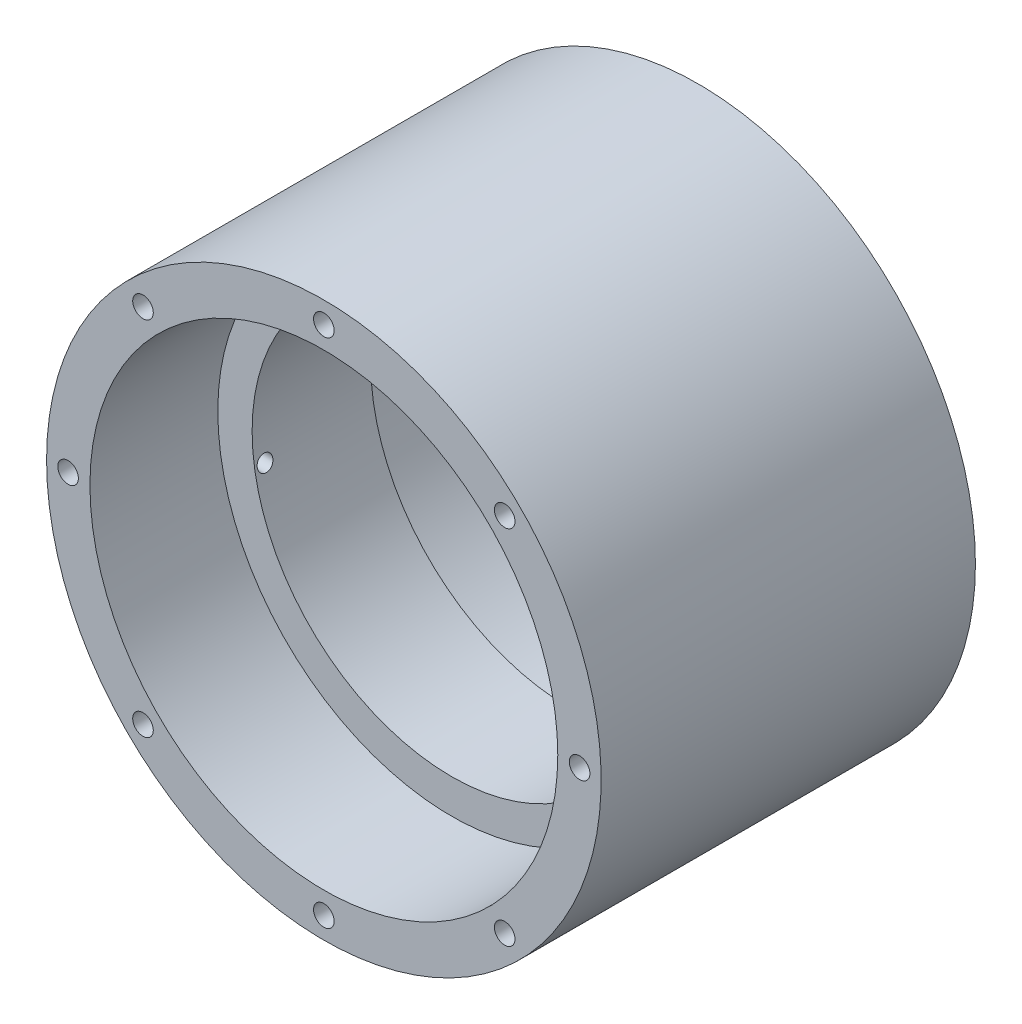
from build123d import *

# Parameters (mm, degrees)
SKETCH1_W                  = 44.45
SKETCH1_H                  = 60
CUT_EXTRUDE1_DEPTH         = 50
F_4_CLEARANCE_HOLE1_D      = 3.3
F_4_CLEARANCE_HOLE1_DEPTH  = 8
F_2_CLEARANCE_HOLE1_REACH  = 117.544
F_2_CLEARANCE_HOLE1_BORE_R = 1.25
F_2_CLEARANCE_HOLE2_REACH  = 117.544
F_2_CLEARANCE_HOLE2_BORE_R = 1.25


with BuildPart() as part:
    # Sketch1 → Revolve1 (revolve)
    with BuildSketch(Plane.XZ, mode=Mode.PRIVATE) as revolve1_sk:
        with Locations((22.225, 30)):
            Rectangle(SKETCH1_W, SKETCH1_H)
    revolve(revolve1_sk.sketch.rotate(Axis((0, 0, 60), (0, 0, -1)), 180), axis=Axis((0, 0, 60), (0, 0, -1)))

    # Sketch2 → Cut-Extrude1 (cut)
    with BuildSketch(Plane(origin=(0, 0, 0), x_dir=(-1, 0, 0), z_dir=(0, 0, -1))):
        with BuildLine():
            Line((43.7241638, 8), (43.7241638, -8))
            ThreePointArc((43.7241638, -8), (44.45, 0), (43.7241638, 8))
        make_face()
    extrude(amount=-CUT_EXTRUDE1_DEPTH, mode=Mode.SUBTRACT)

    # Sketch3 → Cut-Revolve1 (revolve, cut)
    with BuildSketch(Plane.XZ, mode=Mode.PRIVATE) as cut_revolve1_sk:
        Polygon((37.5, 60), (0, 60), (0, 0), (37.5, 0), (37.5, 20.5), (32, 20.5), (32, 39.5), (37.5, 39.5), align=None)
    revolve(cut_revolve1_sk.sketch.rotate(Axis((0, 0, 60), (0, 0, -1)), 180), axis=Axis((0, 0, 60), (0, 0, -1)), mode=Mode.SUBTRACT)

    # #4 Clearance Hole1
    with Locations(Plane.XY.offset(60)):
        with Locations((28.991378029, 28.991378029), (0, 41), (-28.991378029, 28.991378029), (-41, 0), (-28.991378029, -28.991378029), (0, -41), (28.991378029, -28.991378029), (41, 0)):
            Hole(F_4_CLEARANCE_HOLE1_D / 2, depth=F_4_CLEARANCE_HOLE1_DEPTH)

    # #2 Clearance Hole1 bore → #2 Clearance Hole1 (cut, up to next)
    with BuildSketch(Plane.ZY.offset(43.7241638), mode=Mode.PRIVATE) as f_2_clearance_hole1_sk1:
        with Locations((15.584748033, 5.15)):
            Circle(F_2_CLEARANCE_HOLE1_BORE_R)
    f_2_clearance_hole1_tool1 = extrude(f_2_clearance_hole1_sk1.sketch, amount=-F_2_CLEARANCE_HOLE1_REACH, mode=Mode.PRIVATE) & part.part
    add(f_2_clearance_hole1_tool1.solids().sort_by_distance((-43.724164, 5.15, 15.584748))[0], mode=Mode.SUBTRACT)

    # #2 Clearance Hole2 bore → #2 Clearance Hole2 (cut, up to next)
    with BuildSketch(Plane.ZY.offset(43.7241638), mode=Mode.PRIVATE) as f_2_clearance_hole2_sk1:
        with Locations((37.834748033, -5.05)):
            Circle(F_2_CLEARANCE_HOLE2_BORE_R)
    f_2_clearance_hole2_tool1 = extrude(f_2_clearance_hole2_sk1.sketch, amount=-F_2_CLEARANCE_HOLE2_REACH, mode=Mode.PRIVATE) & part.part
    add(f_2_clearance_hole2_tool1.solids().sort_by_distance((-43.724164, -5.05, 37.834748))[0], mode=Mode.SUBTRACT)


solid = part.part
